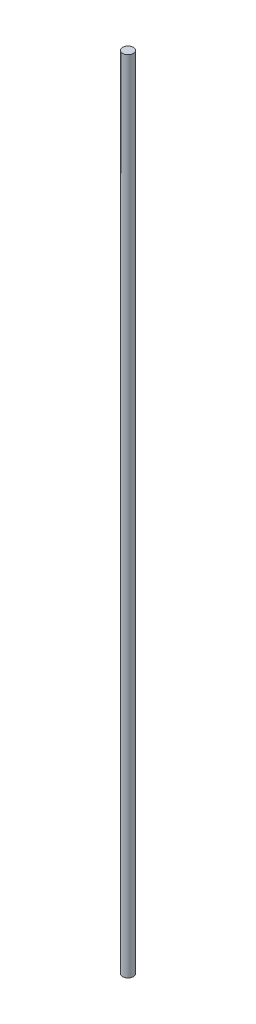
from build123d import *

# Parameters (mm, degrees)
SKETCH1_R           = 1
BOSS_EXTRUDE2_DEPTH = 150


with BuildPart() as part:
    # Sketch1 → Boss-Extrude2 (new body)
    with BuildSketch(Plane(origin=(0, 0, 0), x_dir=(1, 0, 0), z_dir=(0, 1, 0))):
        Circle(SKETCH1_R)
    extrude(amount=BOSS_EXTRUDE2_DEPTH)


solid = part.part
